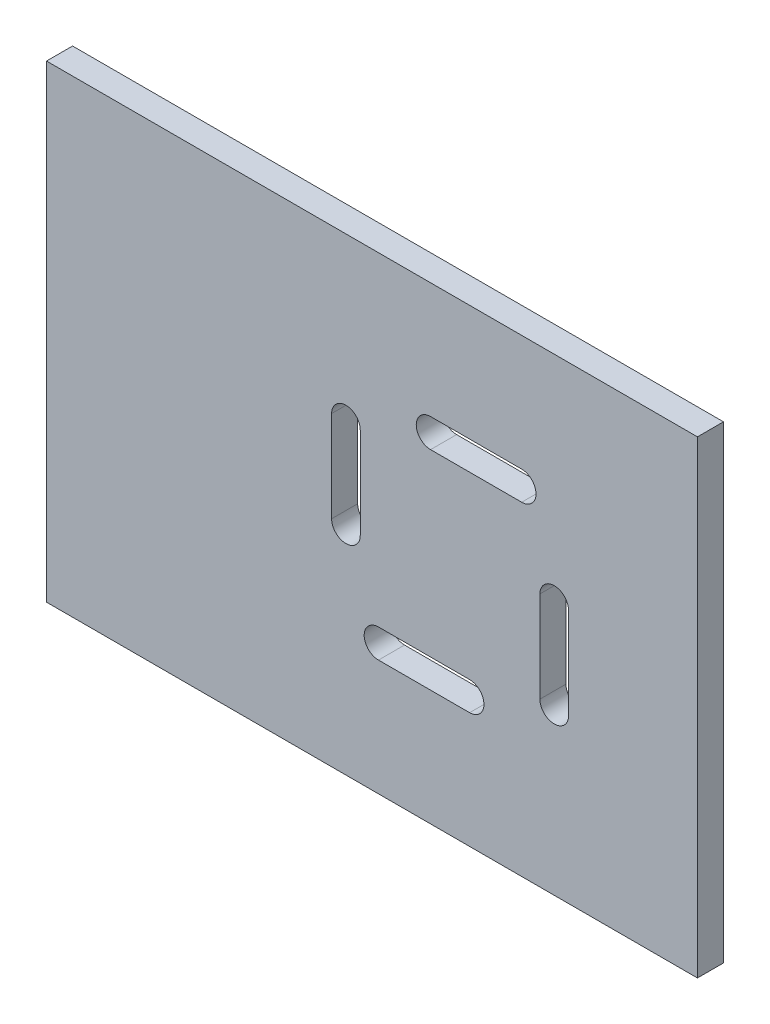
from build123d import *

# Parameters (mm, degrees)
SKETCH1_W           = 250
SKETCH1_H           = 180
BOSS_EXTRUDE1_DEPTH = 10
CUT_EXTRUDE1_DEPTH  = 10
CIRPATTERN1_COUNT   = 4


with BuildPart() as part:
    # Sketch1 → Boss-Extrude1 (new body)
    with BuildSketch(Plane.XY):
        with Locations((75, -50)):
            Rectangle(SKETCH1_W, SKETCH1_H)
    extrude(amount=BOSS_EXTRUDE1_DEPTH)

    # Sketch2 → Cut-Extrude1 (cut)
    with BuildSketch(Plane.XY.offset(10)):
        with BuildLine():
            Line((70.5, -22.5), (70.5, -57.5))
            ThreePointArc((70.5, -57.5), (65, -63), (59.5, -57.5))
            Line((59.5, -57.5), (59.5, -22.5))
            ThreePointArc((59.5, -22.5), (65, -17), (70.5, -22.5))
        make_face()
    cut_extrude1 = extrude(amount=-CUT_EXTRUDE1_DEPTH, mode=Mode.SUBTRACT)

    # CirPattern1: Cut-Extrude1 ×4 about axis
    cirpattern1_axis = Axis((105, -50, 0), (0, 0, 1))
    for i in range(1, CIRPATTERN1_COUNT):
        add(cut_extrude1.rotate(cirpattern1_axis, i * 360 / CIRPATTERN1_COUNT), mode=Mode.SUBTRACT)


solid = part.part
